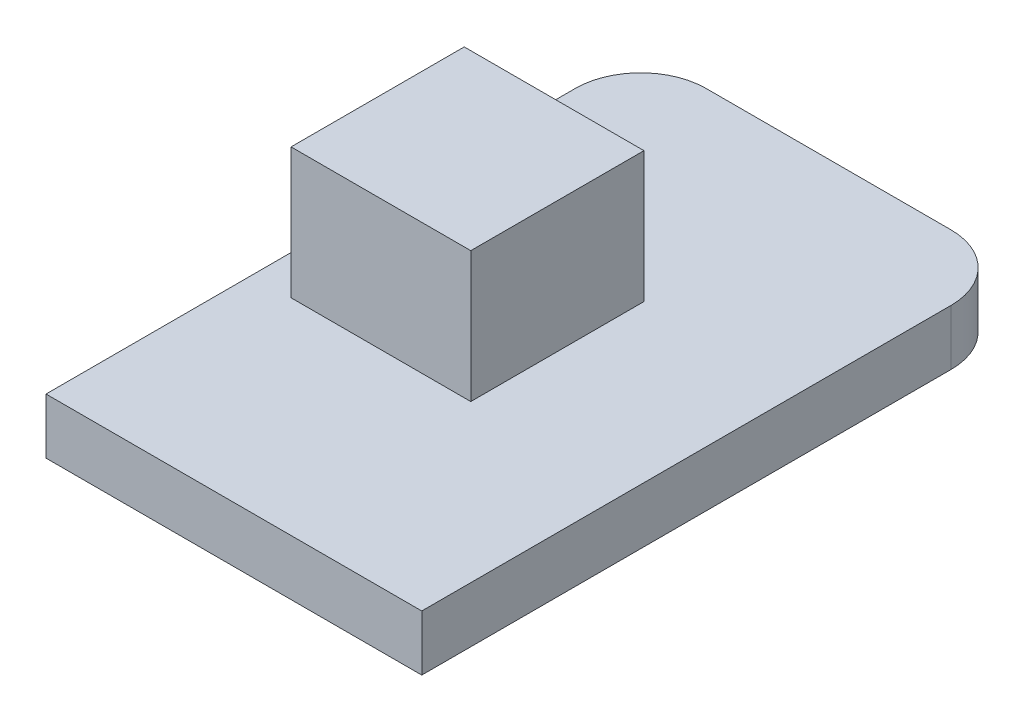
from build123d import *

# Parameters (mm, degrees)
BOSS_EXTRUDE1_DEPTH = 1.7
SKETCH2_W           = 5.5
SKETCH2_H           = 5.3
BOSS_EXTRUDE2_DEPTH = 4


with BuildPart() as part:
    # Sketch1 → Boss-Extrude1 (new body)
    with BuildSketch(Plane(origin=(0, 0, 0), x_dir=(1, 0, 0), z_dir=(0, 1, 0))):
        with BuildLine():
            Line((-3.75, 9.1), (3.75, 9.1))
            ThreePointArc((3.75, 9.1), (5.164213562, 8.514213562), (5.75, 7.1))
            Line((5.75, 7.1), (5.75, -9.1))
            Line((5.75, -9.1), (-5.75, -9.1))
            Line((-5.75, -9.1), (-5.75, 7.1))
            ThreePointArc((-5.75, 7.1), (-5.164213562, 8.514213562), (-3.75, 9.1))
        make_face()
    extrude(amount=BOSS_EXTRUDE1_DEPTH)

    # Sketch2 → Boss-Extrude2 (add)
    with BuildSketch(Plane(origin=(0, 1.7, 0), x_dir=(1, 0, 0), z_dir=(0, 1, 0))):
        with Locations((-1.8, -0.15)):
            Rectangle(SKETCH2_W, SKETCH2_H)
    extrude(amount=BOSS_EXTRUDE2_DEPTH)


solid = part.part
